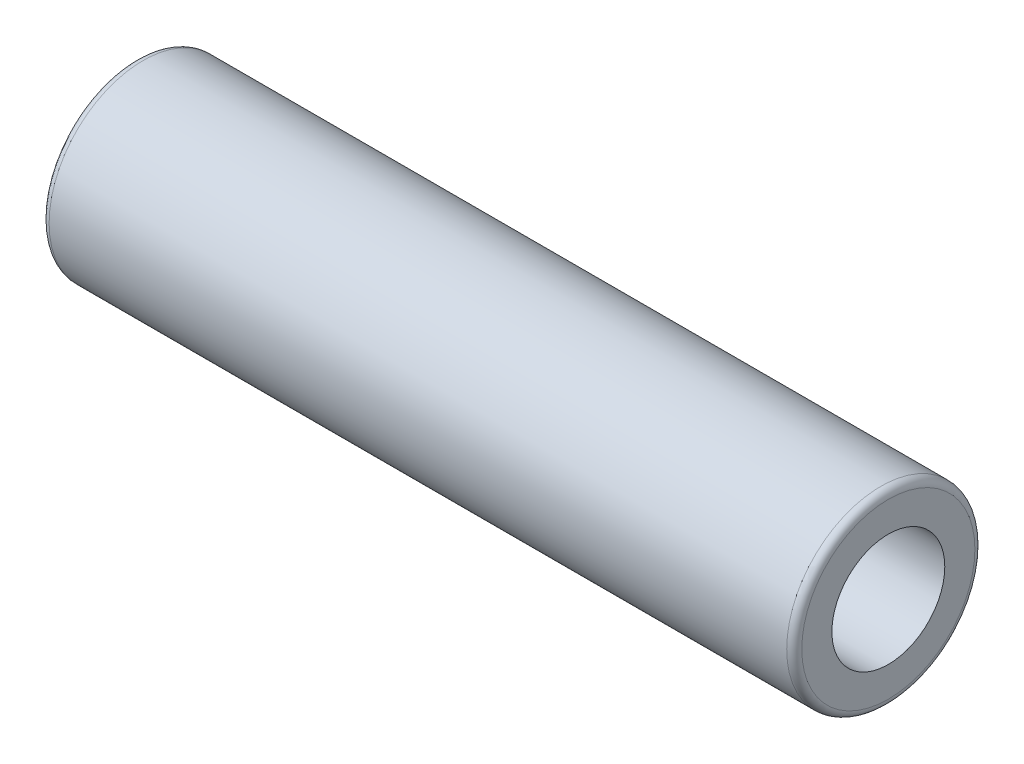
from build123d import *

# Parameters (mm, degrees)
SKETCH1_R           = 6.25
SKETCH1_R_2         = 3.75
BOSS_EXTRUDE2_DEPTH = 50
FILLET1_R           = 0.5
FILLET2_R           = 0.5


with BuildPart() as part:
    # Sketch1 → Boss-Extrude2 (new body)
    with BuildSketch(Plane(origin=(0, 0, 0), x_dir=(0, 0, -1), z_dir=(1, 0, 0))):
        Circle(SKETCH1_R)
        Circle(SKETCH1_R_2, mode=Mode.SUBTRACT)
    extrude(amount=BOSS_EXTRUDE2_DEPTH)

    # Fillet1
    fillet1_edges = [part.edges().sort_by_distance(p)[0] for p in [
        (0, 0, 6.25),
    ]]
    fillet(fillet1_edges, radius=FILLET1_R)

    # Fillet2
    fillet2_edges = [part.edges().sort_by_distance(p)[0] for p in [
        (50, 0, 6.25),
    ]]
    fillet(fillet2_edges, radius=FILLET2_R)


solid = part.part
